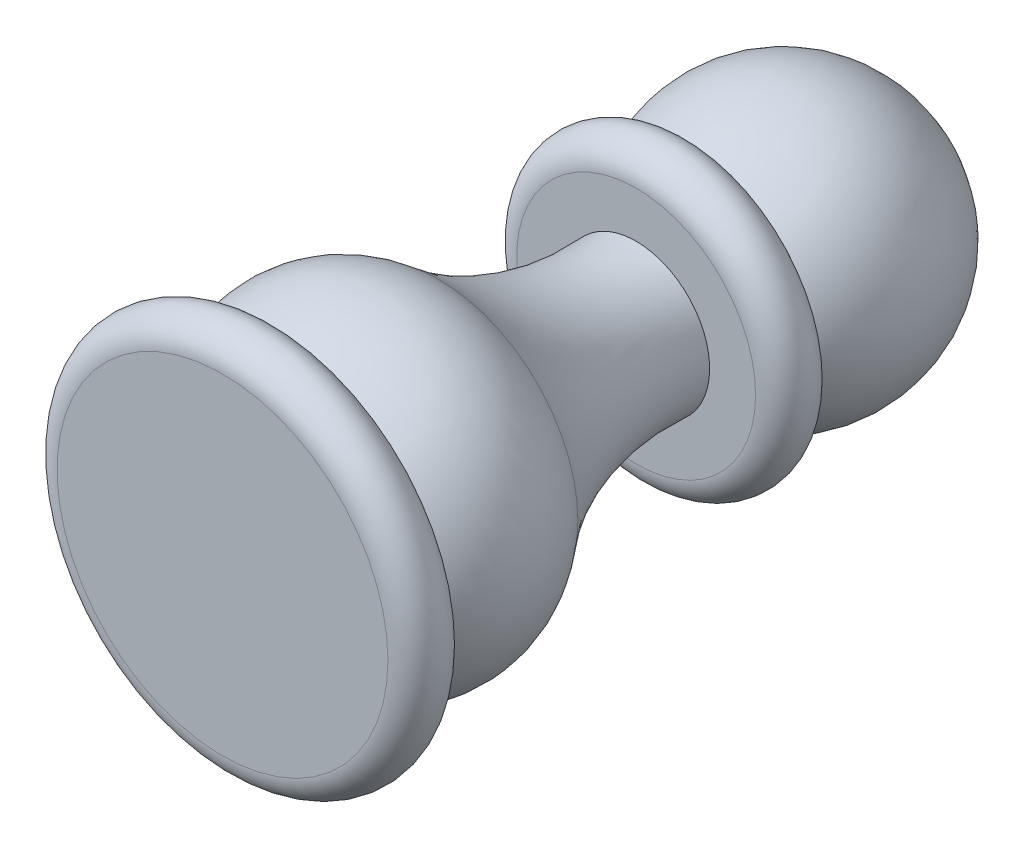
from build123d import *


with BuildPart() as part:
    # Sketch1 → Revolve1 (revolve)
    with BuildSketch(Plane(origin=(0, 0, 0), x_dir=(1, 0, 0), z_dir=(0, 1, 0))):
        with BuildLine():
            ThreePointArc((-4, 21), (-4.731529648, 15.286775193), (-7.562140976, 10.270430623))
            ThreePointArc((-7.562140976, 10.270430623), (-4.015873335, 12.286771959), (0, 11.569549595))
            Line((0, 11.569549595), (0, 21))
            Line((0, 21), (-4, 21))
        make_face()
        with BuildLine():
            ThreePointArc((-7.562140976, 10.270430623), (-8.956479045, 5.652039153), (-6.5, 1.5))
            Line((-6.5, 1.5), (-0.5, 1.5))
            Line((-0.5, 1.5), (0, 1.5))
            Line((0, 1.5), (0, 11.569549595))
            ThreePointArc((0, 11.569549595), (-4.015873335, 12.286771959), (-7.562140976, 10.270430623))
        make_face()
        with BuildLine():
            Line((-6.5, 1.5), (-9, 1.5))
            ThreePointArc((-9, 1.5), (-10.5, 0), (-9, -1.5))
            Line((-9, -1.5), (0, -1.5))
            Line((0, -1.5), (0, 1.17724475))
            ThreePointArc((0, 1.17724475), (-0.254004108, 1.332419364), (-0.5, 1.5))
            Line((-0.5, 1.5), (-6.5, 1.5))
        make_face()
        with BuildLine():
            ThreePointArc((-4.507066567, 24), (-4.177272904, 22.512889696), (-4, 21))
            Line((-4, 21), (0, 21))
            Line((0, 21), (0, 24))
            Line((0, 24), (-4.507066567, 24))
        make_face()
        with BuildLine():
            Line((-5.590169944, 24), (-4.507066567, 24))
            Line((-4.507066567, 24), (0, 24))
            Line((0, 24), (0, 36.5))
            ThreePointArc((0, 36.5), (-6.846531969, 32.061862178), (-5.590169944, 24))
        make_face()
        with BuildLine():
            Line((-6.5, 21), (-4, 21))
            ThreePointArc((-4, 21), (-4.177272904, 22.512889696), (-4.507066567, 24))
            Line((-4.507066567, 24), (-5.590169944, 24))
            Line((-5.590169944, 24), (-6.5, 24))
            ThreePointArc((-6.5, 24), (-8, 22.5), (-6.5, 21))
        make_face()
    revolve(axis=Axis((0, 0, 1.5), (0, 0, -1)))


solid = part.part
